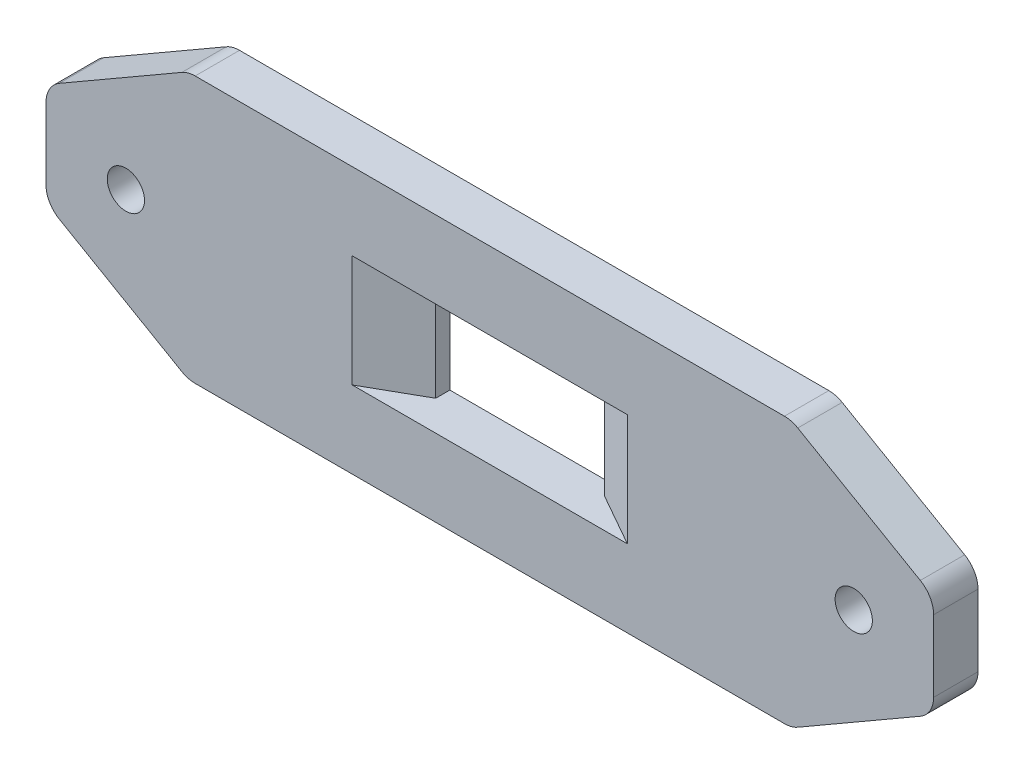
from build123d import *

# Parameters (mm, degrees)
SKETCH1_W             = 100
SKETCH1_H             = 30
BOSS_EXTRUDE1_DEPTH   = 5
CHAMFER1_SIZE         = 16
CHAMFER1_SIZE2        = 9.237604307
CHAMFER1_PART_2_SIZE  = 16
CHAMFER1_PART_2_SIZE2 = 9.237604307
FILLET1_R             = 3
SKETCH2_R             = 2.1
CUT_EXTRUDE1_DEPTH    = 6
SKETCH3_W             = 19
SKETCH3_H             = 12.6
CUT_EXTRUDE2_DEPTH    = 6
CHAMFER2_SIZE         = 6
CHAMFER2_SIZE2        = 3.4


with BuildPart() as part:
    # Sketch1 → Boss-Extrude1 (new body)
    with BuildSketch(Plane.XY):
        with Locations((-50, 15)):
            Rectangle(SKETCH1_W, SKETCH1_H)
    extrude(amount=BOSS_EXTRUDE1_DEPTH)

    # Chamfer1
    chamfer1_edges = [part.edges().sort_by_distance(p)[0] for p in [
        (0, 0, 2.5),
        (-100, 0, 2.5),
    ]]
    chamfer1_side = [part.faces().sort_by_distance(p)[0] for p in [
        (-50, 0, 2.5),
    ]]
    chamfer(chamfer1_edges, length=CHAMFER1_SIZE, length2=CHAMFER1_SIZE2, reference=chamfer1_side[0])

    # Chamfer1 part 2
    chamfer1_part_2_edges = [part.edges().sort_by_distance(p)[0] for p in [
        (-100, 30, 2.5),
        (0, 30, 2.5),
    ]]
    chamfer1_part_2_side = [part.faces().sort_by_distance(p)[0] for p in [
        (-50, 30, 2.5),
    ]]
    chamfer(chamfer1_part_2_edges, length=CHAMFER1_PART_2_SIZE, length2=CHAMFER1_PART_2_SIZE2, reference=chamfer1_part_2_side[0])

    # Fillet1
    fillet1_edges = [part.edges().sort_by_distance(p)[0] for p in [
        (-84, 30, 2.5),
        (-16, 30, 2.5),
        (0, 9.237604307, 2.5),
        (0, 20.762395693, 2.5),
        (-84, 0, 2.5),
        (-16, 0, 2.5),
        (-100, 20.762395693, 2.5),
        (-100, 9.237604307, 2.5),
    ]]
    fillet(fillet1_edges, radius=FILLET1_R)

    # Sketch2 → Cut-Extrude1 (cut, through all)
    with BuildSketch(Plane.XY.offset(5)):
        with Locations((-91, 15)):
            Circle(SKETCH2_R)
        with Locations((-9, 15)):
            Circle(SKETCH2_R)
    extrude(amount=-CUT_EXTRUDE1_DEPTH, mode=Mode.SUBTRACT)

    # Sketch3 → Cut-Extrude2 (cut, through all)
    with BuildSketch(Plane.XY.offset(5)):
        with Locations((-50, 15)):
            Rectangle(SKETCH3_W, SKETCH3_H)
    extrude(amount=-CUT_EXTRUDE2_DEPTH, mode=Mode.SUBTRACT)

    # Chamfer2
    chamfer2_edges = [part.edges().sort_by_distance(p)[0] for p in [
        (-59.5, 15, 5),
        (-40.5, 15, 5),
    ]]
    chamfer2_side = [part.faces().sort_by_distance(p)[0] for p in [
        (-1.044030651, 15, 5),
    ]]
    chamfer(chamfer2_edges, length=CHAMFER2_SIZE, length2=CHAMFER2_SIZE2, reference=chamfer2_side[0])


solid = part.part
